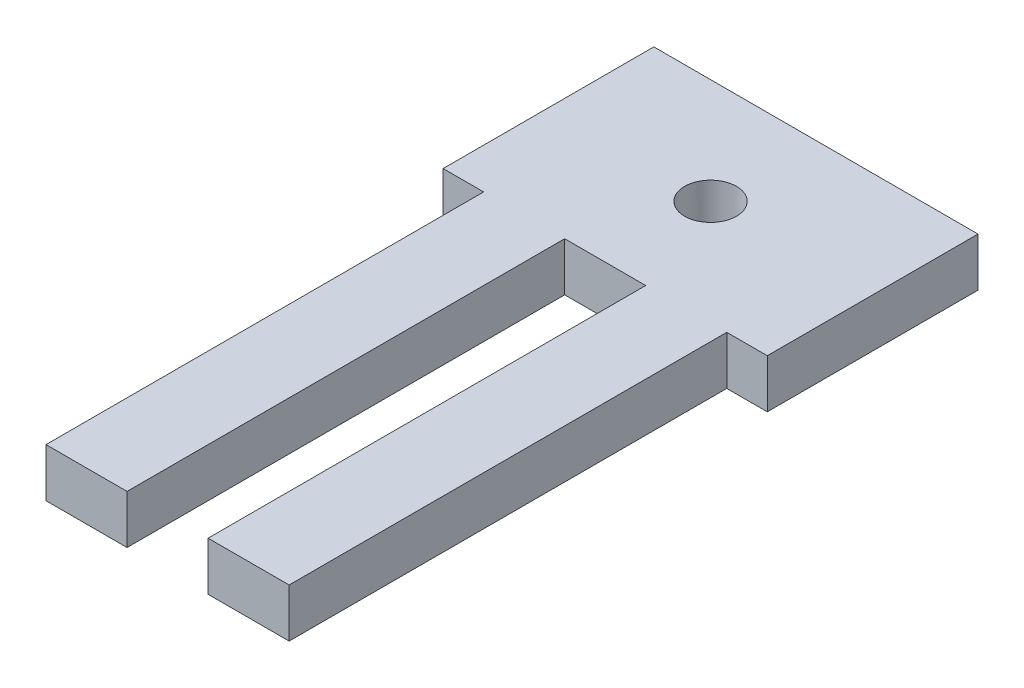
from build123d import *

# Parameters (mm, degrees)
SKETCH1_W               = 20
SKETCH1_H               = 40
BOSS_EXTRUDE1_DEPTH     = 3
SKETCH2_W               = 2.5
SKETCH2_H               = 27
CUT_EXTRUDE1_DEPTH      = 3
SKETCH3_R               = 1.6
CUT_EXTRUDE2_DEPTH      = 1
CUT_EXTRUDE2_DEPTH_BACK = 4
SKETCH4_W               = 5
SKETCH4_H               = 27
CUT_EXTRUDE3_DEPTH      = 1
CUT_EXTRUDE3_DEPTH_BACK = 4


with BuildPart() as part:
    # Sketch1 → Boss-Extrude1 (new body)
    with BuildSketch(Plane(origin=(0, 0, 0), x_dir=(1, 0, 0), z_dir=(0, 1, 0))):
        with Locations((10, 20)):
            Rectangle(SKETCH1_W, SKETCH1_H)
    extrude(amount=BOSS_EXTRUDE1_DEPTH)

    # Sketch2 → Cut-Extrude1 (cut)
    with BuildSketch(Plane(origin=(0, 3, 0), x_dir=(1, 0, 0), z_dir=(0, 1, 0))):
        with Locations((1.25, 13.5)):
            Rectangle(SKETCH2_W, SKETCH2_H)
    cut_extrude1 = extrude(amount=-CUT_EXTRUDE1_DEPTH, mode=Mode.SUBTRACT)

    # Mirror1: Cut-Extrude1 across plane
    add(cut_extrude1.mirror(Plane.ZY.offset(-10)), mode=Mode.SUBTRACT)

    # Sketch3 → Cut-Extrude2 (cut, two sides)
    with BuildSketch(Plane(origin=(0, 3, 0), x_dir=(1, 0, 0), z_dir=(0, 1, 0))) as cut_extrude2_sk:
        with Locations((10, 33.5)):
            Circle(SKETCH3_R)
    extrude(amount=CUT_EXTRUDE2_DEPTH, mode=Mode.SUBTRACT)
    extrude(cut_extrude2_sk.sketch, amount=-CUT_EXTRUDE2_DEPTH_BACK, mode=Mode.SUBTRACT)

    # Sketch4 → Cut-Extrude3 (cut, two sides)
    with BuildSketch(Plane(origin=(0, 3, 0), x_dir=(1, 0, 0), z_dir=(0, 1, 0))) as cut_extrude3_sk:
        with Locations((10, 13.5)):
            Rectangle(SKETCH4_W, SKETCH4_H)
    extrude(amount=CUT_EXTRUDE3_DEPTH, mode=Mode.SUBTRACT)
    extrude(cut_extrude3_sk.sketch, amount=-CUT_EXTRUDE3_DEPTH_BACK, mode=Mode.SUBTRACT)


solid = part.part
